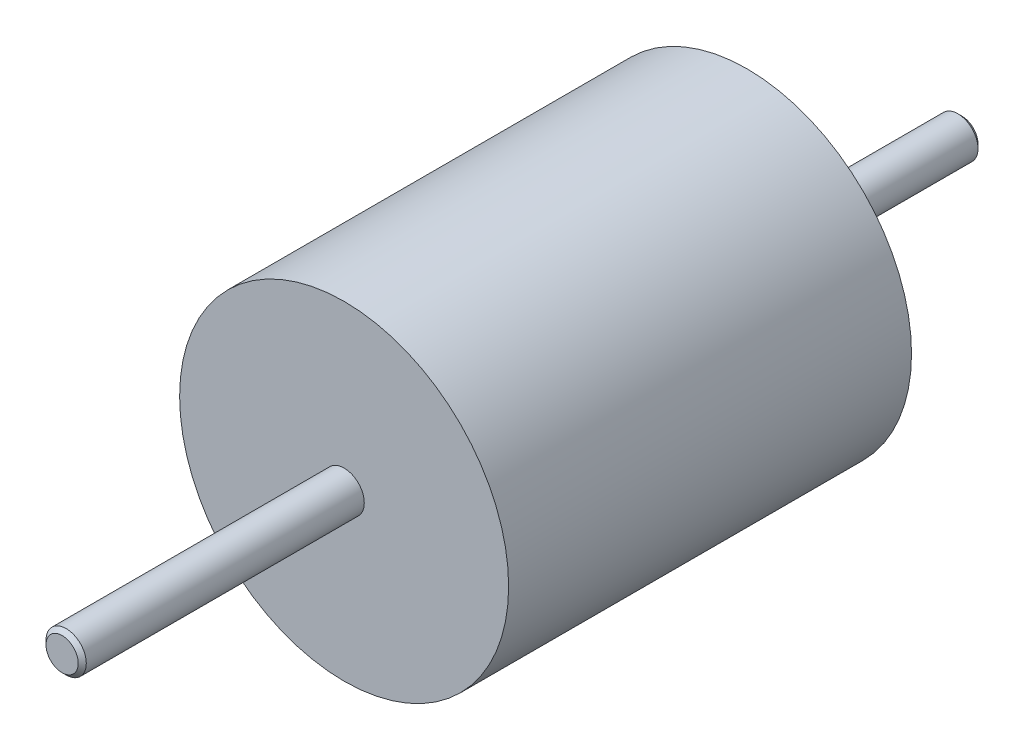
from build123d import *

# Parameters (mm, degrees)
SKETCH1_R           = 1.5
BOSS_EXTRUDE1_DEPTH = 33.5
SKETCH2_R           = 12.25
SKETCH2_R_2         = 1.5
BOSS_EXTRUDE2_DEPTH = 30
CHAMFER1_SIZE       = 0.3


with BuildPart() as part:
    # Sketch1 → Boss-Extrude1 (new body, symmetric)
    with BuildSketch(Plane.XY):
        Circle(SKETCH1_R)
    extrude(amount=BOSS_EXTRUDE1_DEPTH, both=True)

    # Sketch2 → Boss-Extrude2 (add)
    with BuildSketch(Plane.XY.offset(12.5)):
        Circle(SKETCH2_R)
        Circle(SKETCH2_R_2, mode=Mode.SUBTRACT)
    extrude(amount=-BOSS_EXTRUDE2_DEPTH)

    # Chamfer1
    chamfer1_edges = [part.edges().sort_by_distance(p)[0] for p in [
        (-1.5, 0, -33.5),
        (-1.5, 0, 33.5),
    ]]
    chamfer(chamfer1_edges, length=CHAMFER1_SIZE)


solid = part.part
